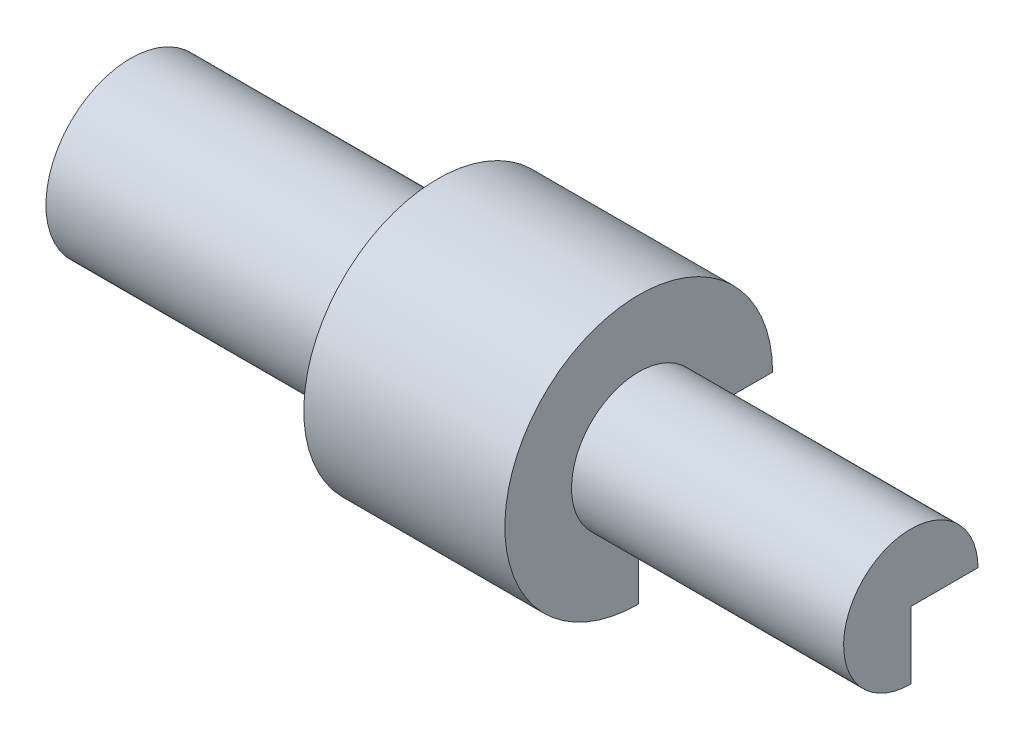
from build123d import *

# Parameters (mm, degrees)
REVOLVE4_ANGLE = 270


with BuildPart() as part:
    # Sketch1 → Revolve4 (revolve)
    with BuildSketch(Plane(origin=(0, 0, 0), x_dir=(1, 0, 0), z_dir=(0, 1, 0))):
        Polygon((0, 32.550341736), (0, 0), (15.19362108, 0), (15.19362108, 18.201077386), (199.080833898, 18.201077386), (199.080833898, 9.100538693), (279.725137873, 9.100538693), (279.725137873, 0), (299.890300867, 0), (299.890300867, 25.830271184), (195.302050415, 25.830271184), (195.302050415, 51.450540163), (118.021239068, 51.450540163), (118.021239068, 32.550341736), align=None)
    revolve(axis=Axis((0, 0, 0), (1, 0, 0)), revolution_arc=REVOLVE4_ANGLE)


solid = part.part
